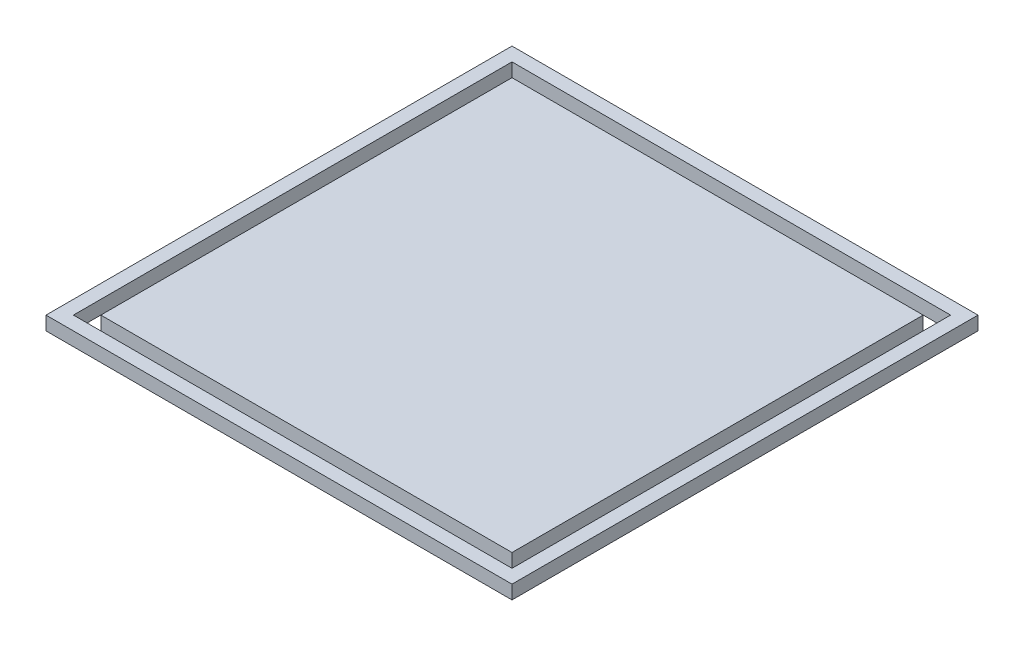
from build123d import *

# Parameters (mm, degrees)
SKETCH1_W           = 150
SKETCH1_H           = 150
BOSS_EXTRUDE1_DEPTH = 10


with BuildPart() as part:
    # Sketch1 → Boss-Extrude1 (new body)
    with BuildSketch(Plane(origin=(0, 0, 0), x_dir=(1, 0, 0), z_dir=(0, 1, 0))):
        Polygon((170, -170), (-170, -170), (-170, 0), (-170, 170), (170, 170), align=None)
        Polygon((160, -160), (-160, -160), (-160, 0), (-160, 160), (160, 160), align=None, mode=Mode.SUBTRACT)
        with Locations((-75, -75)):
            Rectangle(SKETCH1_W, SKETCH1_H)
        with Locations((-75, 75)):
            Rectangle(SKETCH1_W, SKETCH1_H)
        with Locations((75, 75)):
            Rectangle(SKETCH1_W, SKETCH1_H)
        with Locations((75, -75)):
            Rectangle(SKETCH1_W, SKETCH1_H)
    extrude(amount=BOSS_EXTRUDE1_DEPTH)


solid = part.part
